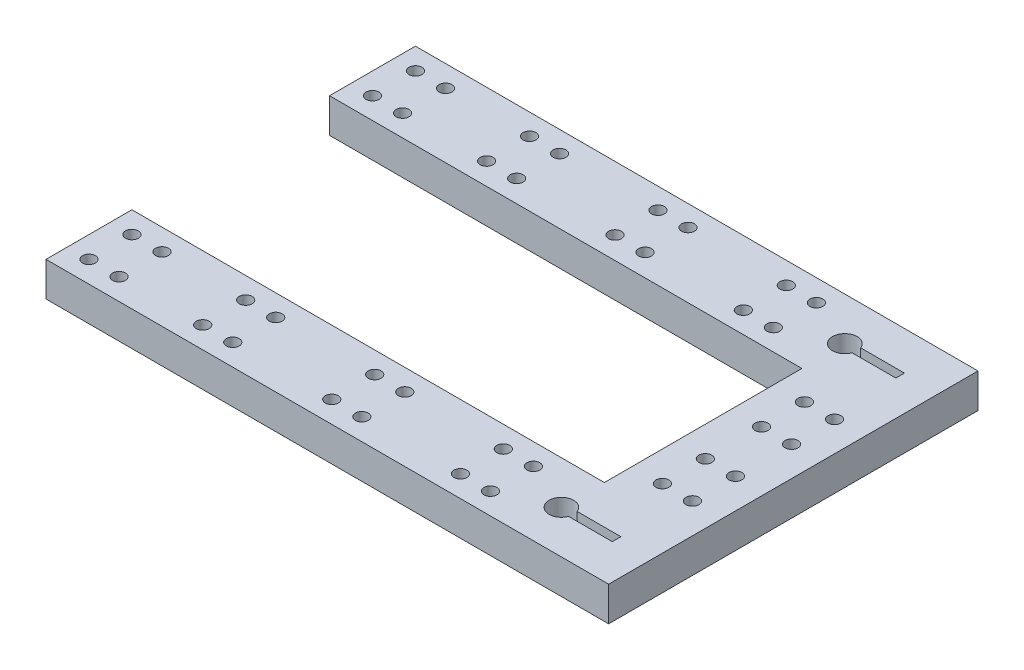
from build123d import *

# Parameters (mm, degrees)
SKETCH1_R           = 1.5
BOSS_EXTRUDE1_DEPTH = 8


with BuildPart() as part:
    # Sketch1 → Boss-Extrude1 (new body)
    with BuildSketch(Plane(origin=(0, 0, 0), x_dir=(1, 0, 0), z_dir=(0, 1, 0))):
        Polygon((21, 42.996794864), (21, 22.996794864), (130.982222222, 22.996794864), (130.982222222, -23.003205136), (20.982222222, -23.003205136), (20.982222222, -43.003205136), (151.982222222, -43.003205136), (151.982222222, 42.996794864), align=None)
        with BuildLine():
            ThreePointArc((133.652222222, -34), (128.132224278, -33.006627887), (133.649820291, -32))
            Line((133.649820291, -32), (143.832222222, -32))
            Line((143.832222222, -32), (143.832222222, -34))
            Line((143.832222222, -34), (133.652222222, -34))
        make_face(mode=Mode.SUBTRACT)
        with Locations((25.982222222, -38.003205136)):
            Circle(SKETCH1_R, mode=Mode.SUBTRACT)
        with Locations((32.982222222, -38.003205136)):
            Circle(SKETCH1_R, mode=Mode.SUBTRACT)
        with Locations((52.447128478, -37.978244052)):
            Circle(SKETCH1_R, mode=Mode.SUBTRACT)
        with Locations((59.447128478, -37.978244052)):
            Circle(SKETCH1_R, mode=Mode.SUBTRACT)
        with Locations((82.483268969, -37.971182344)):
            Circle(SKETCH1_R, mode=Mode.SUBTRACT)
        with Locations((89.483268969, -37.971182344)):
            Circle(SKETCH1_R, mode=Mode.SUBTRACT)
        with Locations((112.466817988, -38.005600575)):
            Circle(SKETCH1_R, mode=Mode.SUBTRACT)
        with Locations((119.466817988, -38.005600575)):
            Circle(SKETCH1_R, mode=Mode.SUBTRACT)
        with Locations((137.961991401, -16.468728947)):
            Circle(SKETCH1_R, mode=Mode.SUBTRACT)
        with Locations((144.961991401, -16.468728947)):
            Circle(SKETCH1_R, mode=Mode.SUBTRACT)
        with Locations((137.961991401, -6.468728947)):
            Circle(SKETCH1_R, mode=Mode.SUBTRACT)
        with Locations((144.961991401, -6.468728947)):
            Circle(SKETCH1_R, mode=Mode.SUBTRACT)
        with Locations((26, 27.996794864)):
            Circle(SKETCH1_R, mode=Mode.SUBTRACT)
        with Locations((33, 27.996794864)):
            Circle(SKETCH1_R, mode=Mode.SUBTRACT)
        with Locations((52.451959098, 28.108564772)):
            Circle(SKETCH1_R, mode=Mode.SUBTRACT)
        with Locations((26, 37.996794864)):
            Circle(SKETCH1_R, mode=Mode.SUBTRACT)
        with Locations((33, 37.996794864)):
            Circle(SKETCH1_R, mode=Mode.SUBTRACT)
        with Locations((52.451959098, 38.108564772)):
            Circle(SKETCH1_R, mode=Mode.SUBTRACT)
        with Locations((59.451959098, 28.108564772)):
            Circle(SKETCH1_R, mode=Mode.SUBTRACT)
        with Locations((82.310079685, 28.153226863)):
            Circle(SKETCH1_R, mode=Mode.SUBTRACT)
        with Locations((59.451959098, 38.108564772)):
            Circle(SKETCH1_R, mode=Mode.SUBTRACT)
        with Locations((82.310079685, 38.153226863)):
            Circle(SKETCH1_R, mode=Mode.SUBTRACT)
        with Locations((138.044723892, 6.53090338)):
            Circle(SKETCH1_R, mode=Mode.SUBTRACT)
        with Locations((145.044723892, 6.53090338)):
            Circle(SKETCH1_R, mode=Mode.SUBTRACT)
        with Locations((138.044723892, 16.53090338)):
            Circle(SKETCH1_R, mode=Mode.SUBTRACT)
        with Locations((145.044723892, 16.53090338)):
            Circle(SKETCH1_R, mode=Mode.SUBTRACT)
        with Locations((89.310079685, 28.153226863)):
            Circle(SKETCH1_R, mode=Mode.SUBTRACT)
        with Locations((112.409987019, 27.931087325)):
            Circle(SKETCH1_R, mode=Mode.SUBTRACT)
        with Locations((89.310079685, 38.153226863)):
            Circle(SKETCH1_R, mode=Mode.SUBTRACT)
        with Locations((112.409987019, 37.931087325)):
            Circle(SKETCH1_R, mode=Mode.SUBTRACT)
        with Locations((119.409987019, 27.931087325)):
            Circle(SKETCH1_R, mode=Mode.SUBTRACT)
        with Locations((119.409987019, 37.931087325)):
            Circle(SKETCH1_R, mode=Mode.SUBTRACT)
        with BuildLine():
            ThreePointArc((130.982222222, 35.864572641), (132.618738584, 35.351781823), (133.67, 33.996794864))
            Line((133.67, 33.996794864), (143.85, 33.996794864))
            Line((143.85, 33.996794864), (143.85, 31.996794864))
            Line((143.85, 31.996794864), (133.67, 31.996794864))
            ThreePointArc((133.67, 31.996794864), (128.627235263, 31.360278502), (130.982222222, 35.864572641))
        make_face(mode=Mode.SUBTRACT)
        with Locations((52.447128478, -27.978244052)):
            Circle(SKETCH1_R, mode=Mode.SUBTRACT)
        with Locations((59.447128478, -27.978244052)):
            Circle(SKETCH1_R, mode=Mode.SUBTRACT)
        with Locations((82.483268969, -27.971182344)):
            Circle(SKETCH1_R, mode=Mode.SUBTRACT)
        with Locations((89.483268969, -27.971182344)):
            Circle(SKETCH1_R, mode=Mode.SUBTRACT)
        with Locations((112.466817988, -28.005600575)):
            Circle(SKETCH1_R, mode=Mode.SUBTRACT)
        with Locations((119.466817988, -28.005600575)):
            Circle(SKETCH1_R, mode=Mode.SUBTRACT)
        with Locations((25.982222222, -28.003205136)):
            Circle(SKETCH1_R, mode=Mode.SUBTRACT)
        with Locations((32.982222222, -28.003205136)):
            Circle(SKETCH1_R, mode=Mode.SUBTRACT)
    extrude(amount=BOSS_EXTRUDE1_DEPTH)


solid = part.part
